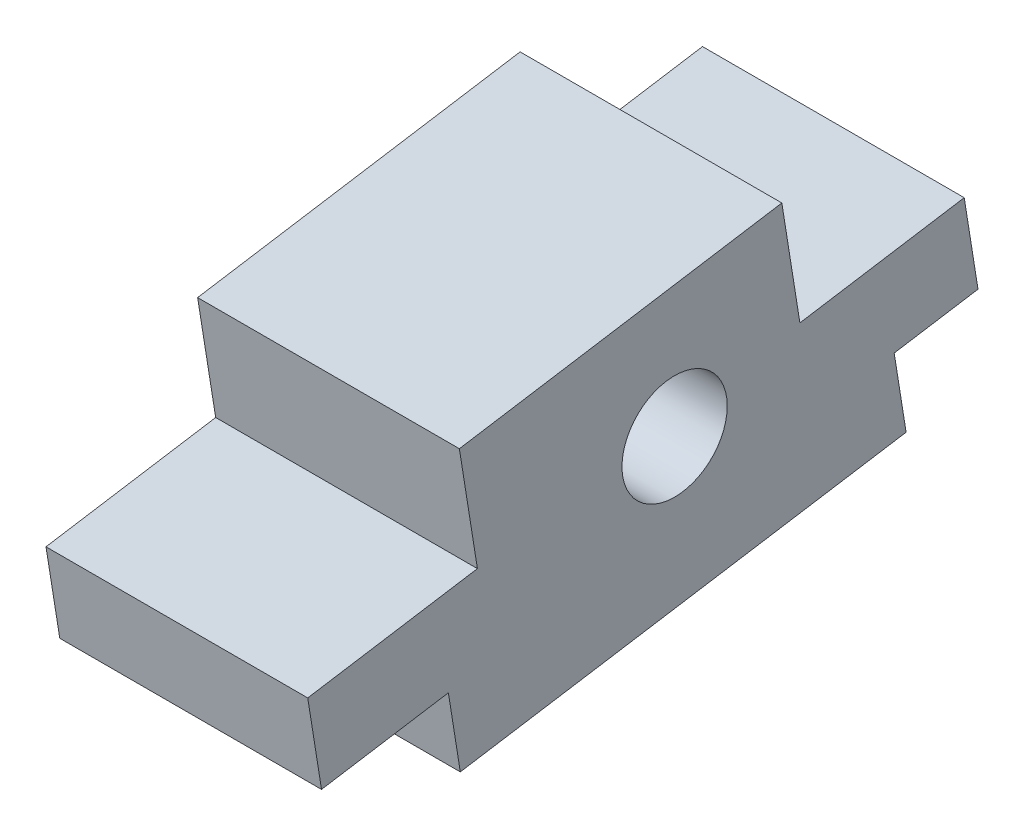
from build123d import *

# Parameters (mm, degrees)
SKETCH1_R           = 6.0325
BOSS_EXTRUDE1_DEPTH = 30


with BuildPart() as part:
    # Sketch1 → Boss-Extrude1 (new body)
    with BuildSketch(Plane(origin=(0, 0, 0), x_dir=(0, 0, -1), z_dir=(1, 0, 0))):
        Polygon((-40.471150755, -14.808149442), (-42.049995036, -4.933573465), (-22.602775287, -1.824160793), (-24.67138994, 11.113589187), (12.290675723, 17.023447605), (14.359290376, 4.085697625), (33.194273914, 7.097219953), (34.773118194, -2.777356025), (25.167363634, -4.313218494), (26.532735292, -12.852671266), (-24.565465971, -21.022754011), (-25.930837628, -12.483301239), align=None)
        Circle(SKETCH1_R, mode=Mode.SUBTRACT)
    extrude(amount=BOSS_EXTRUDE1_DEPTH)


solid = part.part
